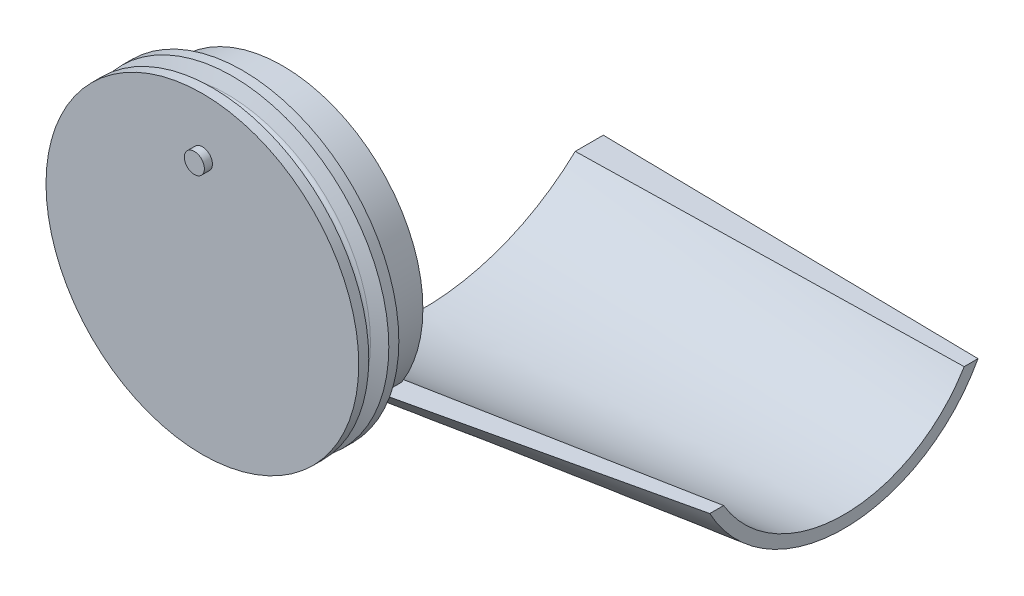
from build123d import *

# Parameters (mm, degrees)
SKETCH1_R           = 35
SKETCH1_R_2         = 15
BOSS_EXTRUDE1_DEPTH = 10
SKETCH5_R           = 35
BOSS_EXTRUDE3_DEPTH = 10
SKETCH4_R           = 2.5
BOSS_EXTRUDE2_DEPTH = 2


with BuildPart() as part:
    # Sketch1 → Boss-Extrude1 (new body)
    with BuildSketch(Plane.XY):
        Circle(SKETCH1_R)
        Circle(SKETCH1_R_2, mode=Mode.SUBTRACT)
    extrude(amount=BOSS_EXTRUDE1_DEPTH)

    # Sketch2 for Loft1 → Loft1 section 0
    with BuildSketch(Plane(origin=(0, 0, 0), x_dir=(0, 0, -1), z_dir=(1, 0, 0))):
        with BuildLine():
            Line((-10, -20), (-2.996710384, -20))
            # circular arc as an exact rational Bezier (weights 1, cos(half-angle), 1)
            Bezier((-2.996710384, -20), (35, -55.538461538), (72.996710384, -20), weights=[1, 0.730337079, 1])
            Line((72.996710384, -20), (80, -20))
            Bezier((80, -20), (35, -69.846153846), (-10, -20), weights=[1, 0.670103093, 1])
        make_face()
    # Sketch3 for Loft1 → Loft1 section 1
    with BuildSketch(Plane(origin=(100, 0, 0), x_dir=(0, 0, -1), z_dir=(1, 0, 0))):
        with BuildLine():
            Line((10, -15), (6.551180448, -15))
            Bezier((6.551180448, -15), (40, -77.258592471), (73.448819552, -15), weights=[1, 0.47327653, 1])
            Line((73.448819552, -15), (70, -15))
            Bezier((70, -15), (40, -65.081833061), (10, -15), weights=[1, 0.513877208, 1])
        make_face()
    loft()

    # Sketch5 → Boss-Extrude3 (add)
    with BuildSketch(Plane.XY.offset(10)):
        with Locations(Location((0, 0, 0), (0, 0, 314.528269686))):
            Circle(SKETCH5_R)
    extrude(amount=BOSS_EXTRUDE3_DEPTH)

    # Sketch7 → Revolve1 (revolve)
    with BuildSketch(Plane.ZY, mode=Mode.PRIVATE) as revolve1_sk:
        with BuildLine():
            Line((20, 34), (20, 39))
            Line((20, 39), (17.5, 39))
            Line((17.5, 39), (16.153846154, 35.769230769))
            ThreePointArc((16.153846154, 35.769230769), (15, 35), (13.846153846, 35.769230769))
            Line((13.846153846, 35.769230769), (12.5, 39))
            Line((12.5, 39), (10, 39))
            Line((10, 39), (10, 34))
            Line((10, 34), (20, 34))
        make_face()
    revolve(revolve1_sk.sketch.rotate(Axis((0, 0, 20), (0, 0, -1)), 90), axis=Axis((0, 0, 20), (0, 0, -1)))

    # Sketch4 → Boss-Extrude2 (add)
    with BuildSketch(Plane.XY.offset(20)):
        with Locations((0, 25)):
            Circle(SKETCH4_R)
    extrude(amount=BOSS_EXTRUDE2_DEPTH)


solid = part.part
